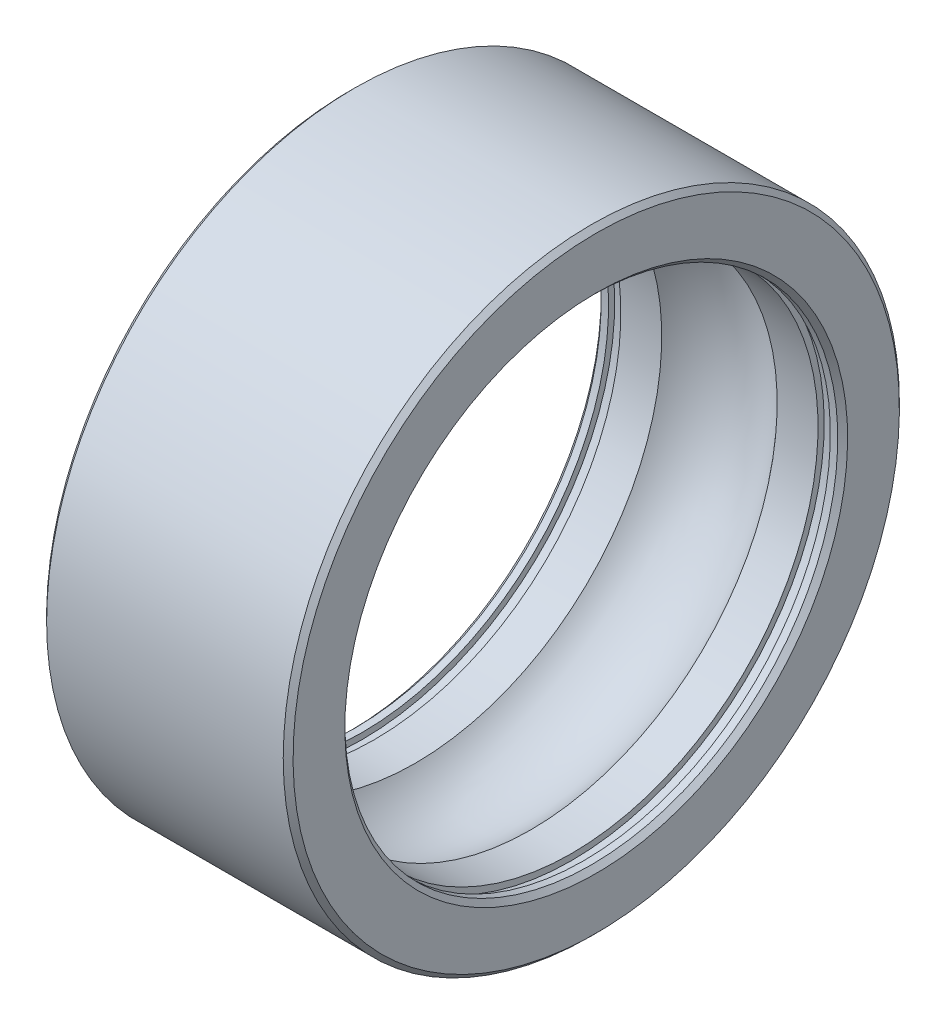
from build123d import *

# Parameters (mm, degrees)
CHAMFER1_SIZE = 0.08


with BuildPart() as part:
    # Sketch1 → Revolve1 (revolve)
    with BuildSketch(Plane.XY):
        with BuildLine():
            Line((-1.6, -4), (-0.9367497, -4))
            ThreePointArc((-0.9367497, -4), (0, -4.45), (0.9367497, -4))
            Line((0.9367497, -4), (1.6, -4))
            Line((1.6, -4), (1.6, -4.1))
            Line((1.6, -4.1), (1.8, -4.1))
            Line((1.8, -4.1), (1.8, -4))
            Line((1.8, -4), (2, -4))
            Line((2, -4), (2, -5))
            Line((2, -5), (-2, -5))
            Line((-2, -5), (-2, -4))
            Line((-2, -4), (-1.8, -4))
            Line((-1.8, -4), (-1.8, -4.1))
            Line((-1.8, -4.1), (-1.6, -4.1))
            Line((-1.6, -4.1), (-1.6, -4))
        make_face()
    revolve(axis=Axis((-6.429017492, 0, 0), (1, 0, 0)))

    # Chamfer1
    chamfer1_edges = [part.edges().sort_by_distance(p)[0] for p in [
        (2, 5, 0),
        (-2, 5, 0),
        (-2, 4, 0),
        (2, 4, 0),
    ]]
    chamfer(chamfer1_edges, length=CHAMFER1_SIZE)


solid = part.part
